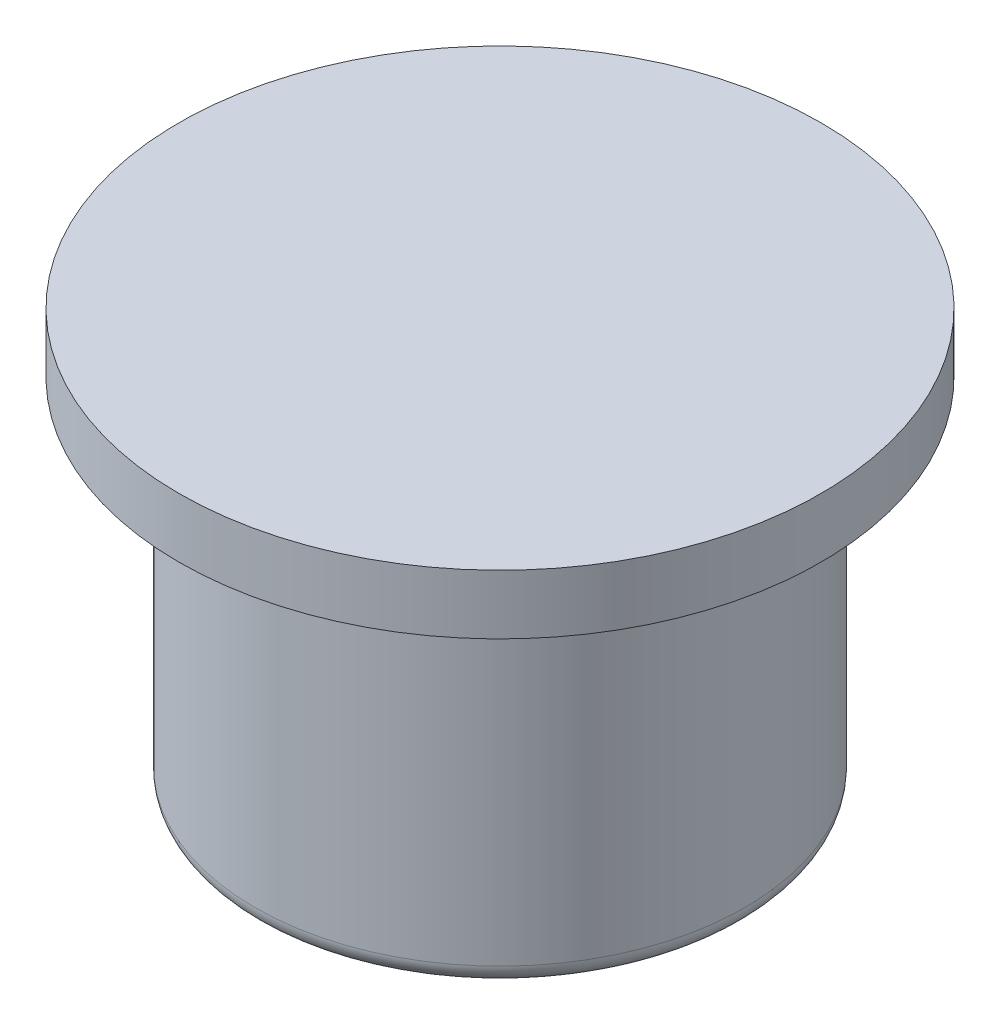
from build123d import *

# Parameters (mm, degrees)
SKETCH1_R           = 3.137422597
BOSS_EXTRUDE1_DEPTH = 4.572
FILLET3_R           = 0.254
SKETCH2_R           = 4.111492789
BOSS_EXTRUDE3_DEPTH = 0.762


with BuildPart() as part:
    # Sketch1 → Boss-Extrude1 (new body)
    with BuildSketch(Plane(origin=(0, 0, 0), x_dir=(1, 0, 0), z_dir=(0, 1, 0))):
        Circle(SKETCH1_R)
    extrude(amount=BOSS_EXTRUDE1_DEPTH)

    # Fillet3
    fillet3_edges = [part.edges().sort_by_distance(p)[0] for p in [
        (-3.137422597, 0, 0),
    ]]
    fillet(fillet3_edges, radius=FILLET3_R)

    # Sketch2 → Boss-Extrude3 (add)
    with BuildSketch(Plane(origin=(0, 4.572, 0), x_dir=(1, 0, 0), z_dir=(0, 1, 0))):
        Circle(SKETCH2_R)
    extrude(amount=BOSS_EXTRUDE3_DEPTH)


solid = part.part
